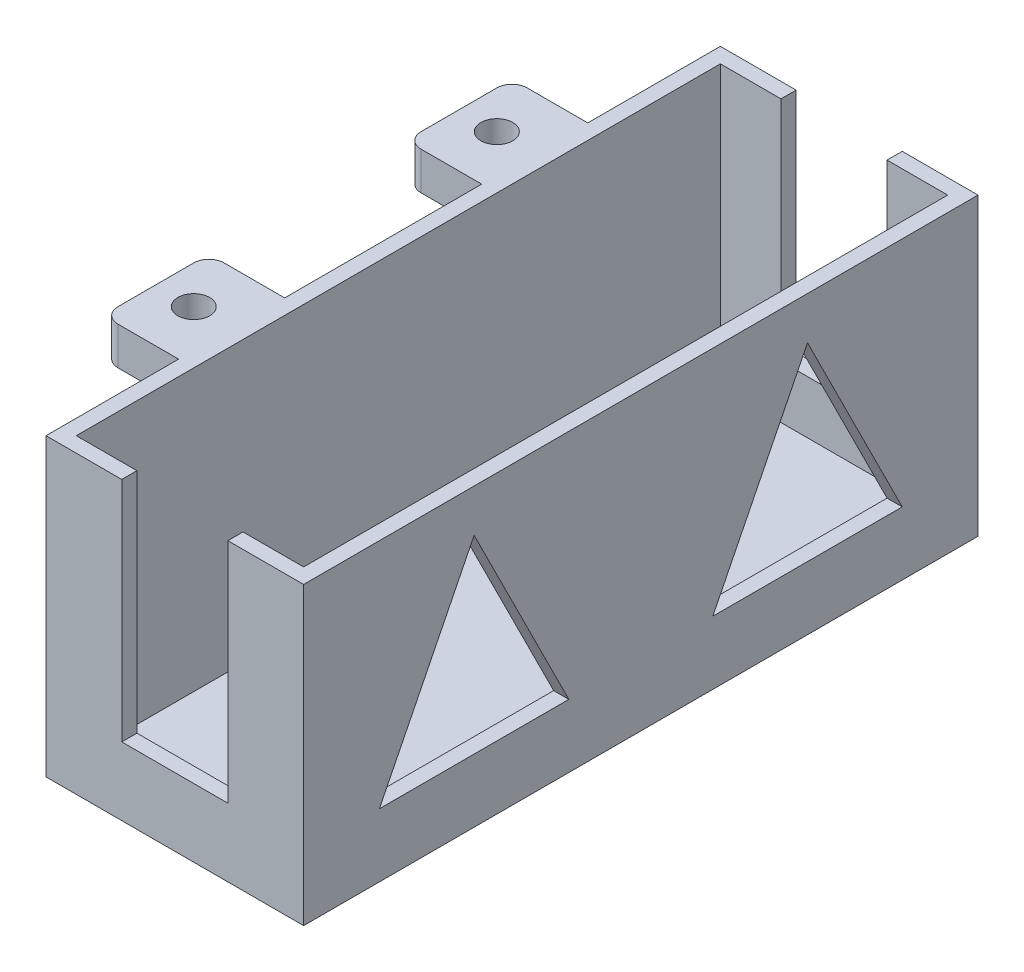
from build123d import *

# Parameters (mm, degrees)
SKETCH2_W             = 10
SKETCH2_H             = 14
SKETCH2_R             = 2.1
BOSS_EXTRUDE1_DEPTH   = 5
BOSS_EXTRUDE1_2_DEPTH = 5
SKETCH3_W             = 44.5
SKETCH3_H             = 39
SKETCH3_W_2           = 14
SKETCH3_H_2           = 5
BOSS_EXTRUDE2_DEPTH   = 2
BOSS_EXTRUDE4_DEPTH   = 32
SKETCH5_W             = 2
SKETCH5_H             = 85
BOSS_EXTRUDE5_DEPTH   = 37
SKETCH6_W             = 14
SKETCH6_H             = 30
CUT_EXTRUDE1_DEPTH    = 200
SKETCH7_W             = 20
SKETCH7_H             = 20
CUT_EXTRUDE2_DEPTH    = 16
FILLET1_R             = 2
SKETCH8_W             = 119.619460544
SKETCH8_H             = 55.607641494
CUT_EXTRUDE3_DEPTH    = 32
SKETCH9_W             = 100
SKETCH9_H             = 35
BOSS_EXTRUDE6_DEPTH   = 2
SKETCH10_W            = 89
SKETCH10_H            = 4
CUT_EXTRUDE4_DEPTH    = 10
BOSS_EXTRUDE7_DEPTH   = 25
SKETCH12_W            = 2
SKETCH12_H            = 35
BOSS_EXTRUDE8_DEPTH   = 2
SKETCH13_W            = 104
SKETCH13_H            = 37
BOSS_EXTRUDE9_DEPTH   = 2
SKETCH14_W            = 13
SKETCH14_H            = 30
CUT_EXTRUDE5_DEPTH    = 104
SKETCH15_W            = 113.891819436
SKETCH15_H            = 51.603678666
CUT_EXTRUDE6_DEPTH    = 27
SKETCH16_W            = 114.232812907
SKETCH16_H            = 49.785046819
CUT_EXTRUDE7_DEPTH    = 2
SKETCH17_W            = 89
SKETCH17_H            = 39
BOSS_EXTRUDE10_DEPTH  = 34
SKETCH18_W            = 30
SKETCH18_H            = 85
CUT_EXTRUDE8_DEPTH    = 37
SKETCH19_W            = 7
SKETCH19_H            = 30
CUT_EXTRUDE9_DEPTH    = 93
CUT_EXTRUDE10_DEPTH   = 17


with BuildPart() as part:
    # Sketch2 → Boss-Extrude1 (new body)
    with BuildSketch(Plane(origin=(0, 0, 0), x_dir=(1, 0, 0), z_dir=(0, 1, 0))):
        with Locations((114.448385229, -132.360414745)):
            Rectangle(SKETCH2_W, SKETCH2_H)
        with Locations((114.448385229, -132.360414745)):
            Circle(SKETCH2_R, mode=Mode.SUBTRACT)
    extrude(amount=BOSS_EXTRUDE1_DEPTH)



with BuildPart() as body_2:
    # Sketch2 → Boss-Extrude1 2 (new body)
    with BuildSketch(Plane(origin=(0, 0, 0), x_dir=(1, 0, 0), z_dir=(0, 1, 0))):
        with Locations((114.448385229, -172.360414745)):
            Rectangle(SKETCH2_W, SKETCH2_H)
        with Locations((114.448385229, -172.360414745)):
            Circle(SKETCH2_R, mode=Mode.SUBTRACT)
    extrude(amount=BOSS_EXTRUDE1_2_DEPTH)


with BuildPart() as part_1:
    add(part.part)

    add(body_2.part)  # Boss-Extrude2 merges body 2
    # Sketch3 → Boss-Extrude2 (add)
    with BuildSketch(Plane(origin=(119.448385229, 0, 0), x_dir=(0, 0, -1), z_dir=(1, 0, 0))):
        Polygon((-152.360414745, -34), (-152.360414745, 5), (-165.360414745, 5), (-165.360414745, 0), (-179.360414745, 0), (-179.360414745, 5), (-196.860414745, 5), (-196.860414745, -34), align=None)
        with Locations((-130.110414745, -14.5)):
            Rectangle(SKETCH3_W, SKETCH3_H)
        with Locations((-172.360414745, 2.5)):
            Rectangle(SKETCH3_W_2, SKETCH3_H_2)
    extrude(amount=BOSS_EXTRUDE2_DEPTH)

    # Sketch4 → Boss-Extrude4 (add)
    with BuildSketch(Plane(origin=(121.448385229, 0, 0), x_dir=(0, 0, -1), z_dir=(1, 0, 0))):
        Polygon((-194.860414745, 5), (-196.860414745, 5), (-196.860414745, -34), (-107.860414745, -34), (-107.860414745, 5), (-109.860414745, 5), (-109.860414745, -32), (-194.860414745, -32), align=None)
    extrude(amount=BOSS_EXTRUDE4_DEPTH)

    # Sketch5 → Boss-Extrude5 (add)
    with BuildSketch(Plane(origin=(0, -32, 0), x_dir=(1, 0, 0), z_dir=(0, 1, 0))):
        with Locations((152.448385229, -152.360414745)):
            Rectangle(SKETCH5_W, SKETCH5_H)
    extrude(amount=BOSS_EXTRUDE5_DEPTH)

    # Sketch6 → Cut-Extrude1 (cut)
    with BuildSketch(Plane.XY.offset(196.860414745)):
        with Locations((136.448385229, -10)):
            Rectangle(SKETCH6_W, SKETCH6_H)
    extrude(amount=-CUT_EXTRUDE1_DEPTH, mode=Mode.SUBTRACT)

    # Sketch7 → Cut-Extrude2 (cut)
    with BuildSketch(Plane(origin=(153.448385229, 0, 0), x_dir=(0, 0, -1), z_dir=(1, 0, 0))):
        with Locations((-179.360414745, -14.5)):
            Rectangle(SKETCH7_W, SKETCH7_H)
        with Locations((-152.360414745, -14.5)):
            Rectangle(SKETCH7_W, SKETCH7_H)
        with Locations((-125.360414745, -14.5)):
            Rectangle(SKETCH7_W, SKETCH7_H)
    extrude(amount=-CUT_EXTRUDE2_DEPTH, mode=Mode.SUBTRACT)

    # Fillet1
    fillet1_edges = [part_1.edges().sort_by_distance(p)[0] for p in [
        (109.448385229, 2.5, 139.360414745),
        (109.448385229, 2.5, 125.360414745),
        (109.448385229, 2.5, 179.360414745),
        (109.448385229, 2.5, 165.360414745),
    ]]
    fillet(fillet1_edges, radius=FILLET1_R)

    # Sketch8 → Cut-Extrude3 (cut)
    with BuildSketch(Plane(origin=(153.448385229, 0, 0), x_dir=(0, 0, -1), z_dir=(1, 0, 0))):
        with Locations((-148.578534845, -15.335015755)):
            Rectangle(SKETCH8_W, SKETCH8_H)
    extrude(amount=-CUT_EXTRUDE3_DEPTH, mode=Mode.SUBTRACT)

    # Sketch9 → Boss-Extrude6 (add)
    with BuildSketch(Plane(origin=(121.448385229, 0, 0), x_dir=(0, 0, -1), z_dir=(1, 0, 0))):
        with Locations((-152.360414745, -12.5)):
            Rectangle(SKETCH9_W, SKETCH9_H)
    extrude(amount=-BOSS_EXTRUDE6_DEPTH)

    # Sketch10 → Cut-Extrude4 (cut)
    with BuildSketch(Plane(origin=(121.448385229, 0, 0), x_dir=(0, 0, -1), z_dir=(1, 0, 0))):
        with Locations((-152.360414745, -32)):
            Rectangle(SKETCH10_W, SKETCH10_H)
    extrude(amount=-CUT_EXTRUDE4_DEPTH, mode=Mode.SUBTRACT)



with BuildPart() as body_2_2:
    # Sketch11 → Boss-Extrude7 (new body)
    with BuildSketch(Plane(origin=(121.448385229, 0, 0), x_dir=(0, 0, -1), z_dir=(1, 0, 0))):
        Polygon((-202.360414745, -30), (-202.360414745, 5), (-204.360414745, 5), (-204.360414745, -32), (-100.360414745, -32), (-100.360414745, 5), (-102.360414745, 5), (-102.360414745, -30), align=None)
    extrude(amount=BOSS_EXTRUDE7_DEPTH)


with BuildPart() as part_2:
    add(part_1.part)

    add(body_2_2.part)  # Boss-Extrude8 merges body 2 2
    # Sketch12 → Boss-Extrude8 (add)
    with BuildSketch(Plane.ZY.offset(-121.448385229)):
        with Locations((101.360414745, -12.5)):
            Rectangle(SKETCH12_W, SKETCH12_H)
        Polygon((102.360414745, -30), (100.360414745, -30), (100.360414745, -32), (204.360414745, -32), (204.360414745, -30), (202.360414745, -30), align=None)
        with Locations((203.360414745, -12.5)):
            Rectangle(SKETCH12_W, SKETCH12_H)
    extrude(amount=BOSS_EXTRUDE8_DEPTH)

    # Sketch13 → Boss-Extrude9 (add)
    with BuildSketch(Plane(origin=(146.448385229, 0, 0), x_dir=(0, 0, -1), z_dir=(1, 0, 0))):
        with Locations((-152.360414745, -13.5)):
            Rectangle(SKETCH13_W, SKETCH13_H)
        Polygon((-195.798080738, -22), (-175.798080738, -22), (-185.798080738, -0.554930795), align=None, mode=Mode.SUBTRACT)
        Polygon((-128.922748753, -22), (-118.922748753, -0.554930795), (-108.922748753, -22), align=None, mode=Mode.SUBTRACT)
        Polygon((-162.360414745, -22), (-142.360414745, -22), (-152.360414745, -0.554930795), align=None, mode=Mode.SUBTRACT)
    extrude(amount=BOSS_EXTRUDE9_DEPTH)

    # Sketch14 → Cut-Extrude5 (cut)
    with BuildSketch(Plane(origin=(0, 0, 100.360414745), x_dir=(-1, 0, 0), z_dir=(0, 0, -1))):
        with Locations((-133.948385229, 5)):
            Rectangle(SKETCH14_W, SKETCH14_H)
    extrude(amount=-CUT_EXTRUDE5_DEPTH, mode=Mode.SUBTRACT)

    # Sketch15 → Cut-Extrude6 (cut)
    with BuildSketch(Plane(origin=(148.448385229, 0, 0), x_dir=(0, 0, -1), z_dir=(1, 0, 0))):
        with Locations((-152.246750255, -13.320211528)):
            Rectangle(SKETCH15_W, SKETCH15_H)
    extrude(amount=-CUT_EXTRUDE6_DEPTH, mode=Mode.SUBTRACT)

    # Sketch16 → Cut-Extrude7 (cut)
    with BuildSketch(Plane(origin=(121.448385229, 0, 0), x_dir=(0, 0, -1), z_dir=(1, 0, 0))):
        with Locations((-151.848924539, -14.329503265)):
            Rectangle(SKETCH16_W, SKETCH16_H)
    extrude(amount=-CUT_EXTRUDE7_DEPTH, mode=Mode.SUBTRACT)

    # Sketch17 → Boss-Extrude10 (add)
    with BuildSketch(Plane(origin=(119.448385229, 0, 0), x_dir=(0, 0, -1), z_dir=(1, 0, 0))):
        with Locations((-152.360414745, -14.5)):
            Rectangle(SKETCH17_W, SKETCH17_H)
    extrude(amount=BOSS_EXTRUDE10_DEPTH)

    # Sketch18 → Cut-Extrude8 (cut)
    with BuildSketch(Plane(origin=(0, 5, 0), x_dir=(1, 0, 0), z_dir=(0, 1, 0))):
        with Locations((136.448385229, -152.360414745)):
            Rectangle(SKETCH18_W, SKETCH18_H)
    extrude(amount=-CUT_EXTRUDE8_DEPTH, mode=Mode.SUBTRACT)

    # Sketch19 → Cut-Extrude9 (cut)
    with BuildSketch(Plane.XY.offset(196.860414745)):
        with Locations((132.948385229, -10)):
            Rectangle(SKETCH19_W, SKETCH19_H)
        with Locations((139.948385229, -10)):
            Rectangle(SKETCH19_W, SKETCH19_H)
    extrude(amount=-CUT_EXTRUDE9_DEPTH, mode=Mode.SUBTRACT)

    # Sketch20 → Cut-Extrude10 (cut)
    with BuildSketch(Plane(origin=(153.448385229, 0, 0), x_dir=(0, 0, -1), z_dir=(1, 0, 0))):
        Polygon((-186.860414745, -25.637480673), (-161.860414745, -25.637480673), (-174.360414745, -0.637480673), align=None)
        Polygon((-117.860414745, -25.637480673), (-142.860414745, -25.637480673), (-130.360414745, -0.637480673), align=None)
    extrude(amount=-CUT_EXTRUDE10_DEPTH, mode=Mode.SUBTRACT)


solid = part_2.part
